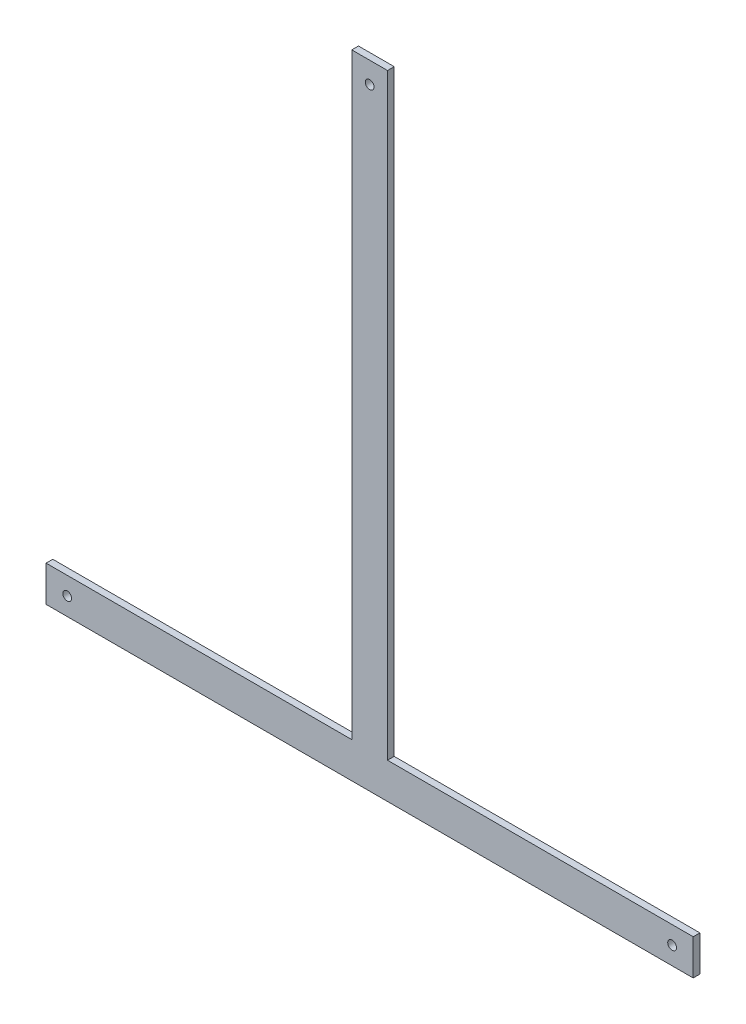
from build123d import *

# Parameters (mm, degrees)
EXTRUDE1_DEPTH     = 4.7625
SKETCH2_R          = 3.125
CUT_EXTRUDE1_DEPTH = 5.7625


with BuildPart() as part:
    # Sketch1 → Extrude1 (new body)
    with BuildSketch(Plane.XY):
        Polygon((-230, 0), (230, 0), (230, 25.4), (12.7, 25.4), (12.7, 450), (-12.7, 450), (-12.7, 25.4), (-230, 25.4), align=None)
    extrude(amount=EXTRUDE1_DEPTH)

    # Sketch2 → Cut-Extrude1 (cut, through all)
    with BuildSketch(Plane.XY.offset(4.7625)):
        with Locations((215, 12.7)):
            Circle(SKETCH2_R)
        with Locations((-215, 12.7)):
            Circle(SKETCH2_R)
        with Locations((0, 435)):
            Circle(SKETCH2_R)
    extrude(amount=-CUT_EXTRUDE1_DEPTH, mode=Mode.SUBTRACT)


solid = part.part
